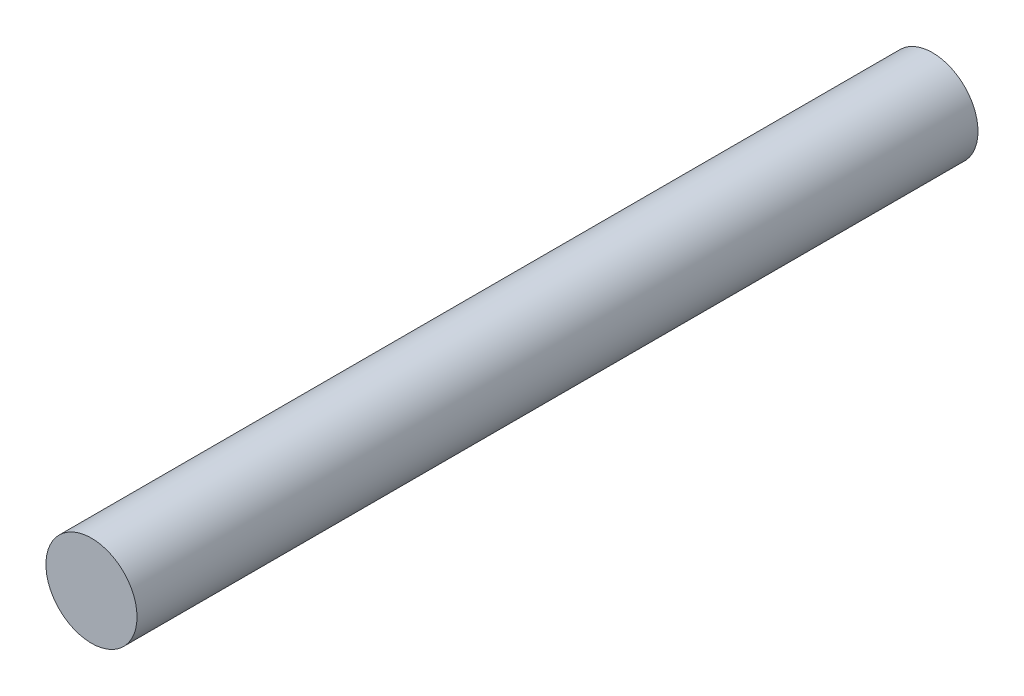
from build123d import *

# Parameters (mm, degrees)
SKETCH1_R           = 6.5
BOSS_EXTRUDE1_DEPTH = 60


with BuildPart() as part:
    # Sketch1 → Boss-Extrude1 (new body, symmetric)
    with BuildSketch(Plane.XY):
        Circle(SKETCH1_R)
    extrude(amount=BOSS_EXTRUDE1_DEPTH, both=True)


solid = part.part
